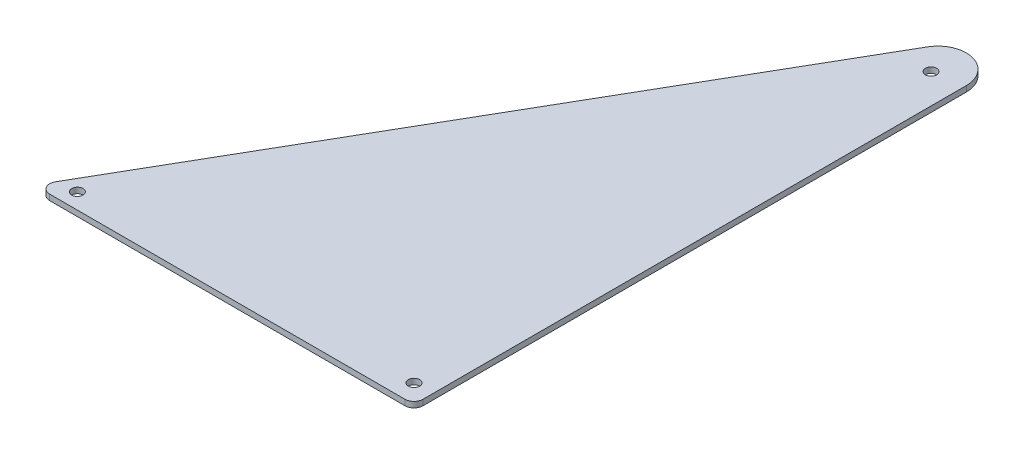
from build123d import *

# Parameters (mm, degrees)
BOSS_EXTRUDE1_DEPTH = 3.175
FILLET1_R           = 5.08
CUT_EXTRUDE2_DEPTH  = 3.175
FILLET2_R           = 5.08
SKETCH4_R           = 3.175
CUT_EXTRUDE3_DEPTH  = 3.175


with BuildPart() as part:
    # Sketch1 → Boss-Extrude1 (new body)
    with BuildSketch(Plane(origin=(0, 0, 0), x_dir=(1, 0, 0), z_dir=(0, 1, 0))):
        Polygon((0, 0), (393.7, 0), (196.85, 340.95420147), align=None)
    extrude(amount=BOSS_EXTRUDE1_DEPTH)

    # Fillet1
    fillet1_edges = [part.edges().sort_by_distance(p)[0] for p in [
        (196.85, 1.5875, -340.95420147),
        (393.7, 1.5875, 0),
        (0, 1.5875, 0),
    ]]
    fillet(fillet1_edges, radius=FILLET1_R)

    # Sketch3 → Cut-Extrude2 (cut)
    with BuildSketch(Plane(origin=(0, 3.175, 0), x_dir=(1, 0, 0), z_dir=(0, 1, 0))):
        with BuildLine():
            Line((389.300590949, 7.62), (210.598153285, 317.14170147))
            ThreePointArc((210.598153285, 317.14170147), (212.184072492, 313.312953811), (212.725, 309.20420147))
            Line((212.725, 309.20420147), (212.725, 0))
            Line((212.725, 0), (384.901181898, 0))
            ThreePointArc((384.901181898, 0), (389.300590949, 2.54), (389.300590949, 7.62))
        make_face()
        with BuildLine():
            Line((210.598153285, 317.14170147), (201.249409051, 333.33420147))
            ThreePointArc((201.249409051, 333.33420147), (196.85, 335.87420147), (192.450590949, 333.33420147))
            Line((192.450590949, 333.33420147), (183.101846715, 317.14170147))
            ThreePointArc((183.101846715, 317.14170147), (196.85, 325.07920147), (210.598153285, 317.14170147))
        make_face()
    extrude(amount=-CUT_EXTRUDE2_DEPTH, mode=Mode.SUBTRACT)

    # Fillet2
    fillet2_edges = [part.edges().sort_by_distance(p)[0] for p in [
        (212.725, 1.5875, 0),
    ]]
    fillet(fillet2_edges, radius=FILLET2_R)

    # Sketch4 → Cut-Extrude3 (cut)
    with BuildSketch(Plane(origin=(0, 3.175, 0), x_dir=(1, 0, 0), z_dir=(0, 1, 0))):
        with Locations((196.028249532, 306.137386971)):
            Circle(SKETCH4_R)
        with Locations((202.256846327, 10.468153673)):
            Circle(SKETCH4_R)
        with Locations((15.397931679, 8.89)):
            Circle(SKETCH4_R)
    extrude(amount=-CUT_EXTRUDE3_DEPTH, mode=Mode.SUBTRACT)


solid = part.part
